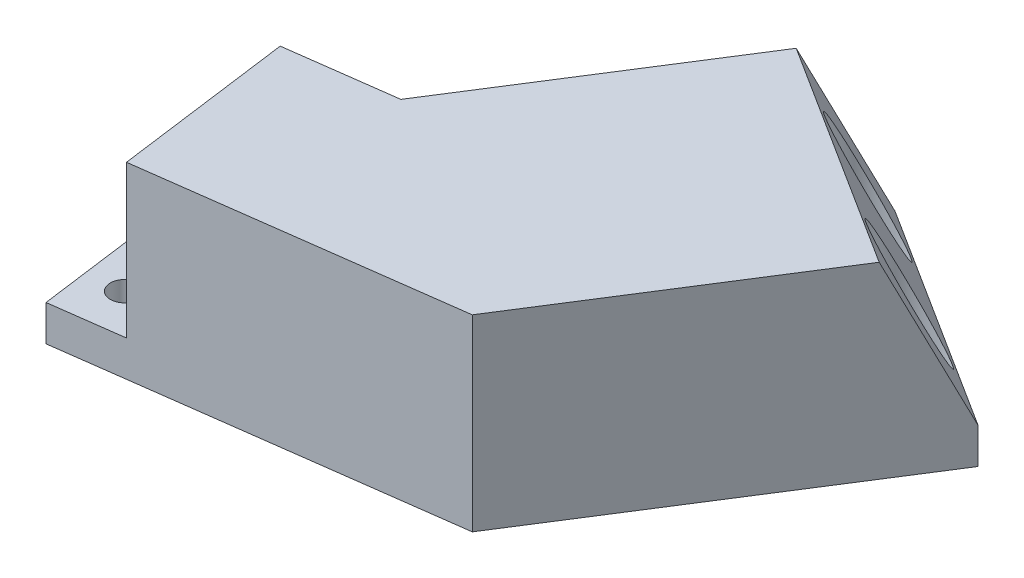
from build123d import *

# Parameters (mm, degrees)
BOSS_EXTRUDE1_DEPTH = 21
CUT_EXTRUDE1_DEPTH  = 17
CUT_EXTRUDE2_START  = -3
CUT_EXTRUDE2_DEPTH  = 19
SKETCH4_R           = 4.5
CUT_EXTRUDE3_DEPTH  = 38.831838053
SKETCH5_R           = 1.6
CUT_EXTRUDE4_DEPTH  = 5
CUT_EXTRUDE5_DEPTH  = 0.5
BOSS_EXTRUDE2_DEPTH = 30
SKETCH10_R          = 1.6
CUT_EXTRUDE6_DEPTH  = 22
CUT_EXTRUDE7_START  = -4
SKETCH11_R          = 3.5
CUT_EXTRUDE7_DEPTH  = 18
SKETCH12_R          = 3
CUT_EXTRUDE8_DEPTH  = 14.628403502
CUT_EXTRUDE9_DEPTH  = 0.5


with BuildPart() as part:
    # Sketch1 → Boss-Extrude1 (new body)
    with BuildSketch(Plane(origin=(0, 0, 0), x_dir=(1, 0, 0), z_dir=(0, 1, 0))):
        Polygon((0, 0), (-19.823417158, -2.651816769), (-17.171600389, -22.475233927), (24.834444629, -16.856004221), (46.756935141, 17.714090893), (21.421674862, 33.78034704), align=None)
    extrude(amount=BOSS_EXTRUDE1_DEPTH)

    # Sketch2 → Cut-Extrude1 (cut)
    with BuildSketch(Plane(origin=(0, 21, 0), x_dir=(1, 0, 0), z_dir=(0, 1, 0))):
        Polygon((21.421674862, 33.78034704), (17.137339889, 27.024277632), (42.472600169, 10.958021485), (46.756935141, 17.714090893), align=None)
        Polygon((-19.823417158, -2.651816769), (-17.171600389, -22.475233927), (-9.242233526, -21.414507219), (-11.894050295, -1.591090061), align=None)
    extrude(amount=-CUT_EXTRUDE1_DEPTH, mode=Mode.SUBTRACT)

    # Sketch3 → Cut-Extrude2 (cut, through all)
    with BuildSketch(Plane(origin=(0, 21, 0), x_dir=(1, 0, 0), z_dir=(0, 1, 0)).offset(CUT_EXTRUDE2_START)):
        Polygon((23.050100429, -14.067976017), (38.332448526, 10.031121072), (18.064240303, 22.884125989), (1.7843442, -2.788028204), (-8.522765206, -4.16683012), (-6.666493468, -18.04322213), align=None)
    extrude(amount=-CUT_EXTRUDE2_DEPTH, mode=Mode.SUBTRACT)

    # Sketch4 → Cut-Extrude3 (cut, through all)
    with BuildSketch(Plane(origin=(2.533526028, 0, 1.606625615), x_dir=(0.535541872, 0, -0.844508676), z_dir=(0.844508676, 0, 0.535541872))):
        with Locations((13.800538513, 9)):
            Circle(SKETCH4_R)
    extrude(amount=-CUT_EXTRUDE3_DEPTH, mode=Mode.SUBTRACT)

    # Sketch5 → Cut-Extrude4 (cut, through all)
    with BuildSketch(Plane(origin=(0, 4, 0), x_dir=(1, 0, 0), z_dir=(0, 1, 0))):
        with Locations((26.035576783, 26.117977363)):
            Circle(SKETCH5_R)
        with Locations((38.703206923, 18.08484929)):
            Circle(SKETCH5_R)
        with Locations((-15.195779534, -7.077307705)):
            Circle(SKETCH5_R)
        with Locations((-13.86987115, -16.989016284)):
            Circle(SKETCH5_R)
    extrude(amount=-CUT_EXTRUDE4_DEPTH, mode=Mode.SUBTRACT)

    # Sketch6 → Cut-Extrude5 (cut)
    with BuildSketch(Plane(origin=(0, 0, 0), x_dir=(-0.535541872, 0, 0.844508676), z_dir=(-0.844508676, 0, -0.535541872))):
        Polygon((-24, 7.5), (-24, 6.888221154), (-24.692307692, 6.635216346), (-24.692307692, 5.483774038), (-24, 5.230769231), (-24, 4.615384615), (-27, 5.749399038), (-27, 6.360576923), align=None)
        Polygon((-25.192307692, 6.451923077), (-26.269230769, 6.057692308), (-25.192307692, 5.664663462), align=None, mode=Mode.SUBTRACT)
        Polygon((-24, 7.923076923), (-27, 7.923076923), (-27, 8.5), (-24.5, 8.5), (-24.5, 10.038461538), (-24, 10.038461538), align=None)
        Polygon((-24, 11.153846154), (-26.5, 11.153846154), (-26.5, 10.269230769), (-27, 10.269230769), (-27, 12.615384615), (-26.5, 12.615384615), (-26.5, 11.730769231), (-24, 11.730769231), align=None)
    extrude(amount=-CUT_EXTRUDE5_DEPTH, mode=Mode.SUBTRACT)

    # Sketch8 → Boss-Extrude2 (add)
    with BuildSketch(Plane(origin=(0, 0, 0), x_dir=(-0.535541872, 0, 0.844508676), z_dir=(-0.844508676, 0, -0.535541872))):
        Polygon((-40, 4), (-32, 21), (-32, 4), align=None)
    extrude(amount=-BOSS_EXTRUDE2_DEPTH)

    # Sketch10 → Cut-Extrude6 (cut, through all)
    with BuildSketch(Plane.XZ):
        with Locations((26.035576783, -26.117977363)):
            Circle(SKETCH10_R)
        with Locations((38.703206923, -18.08484929)):
            Circle(SKETCH10_R)
        with Locations((-15.195779534, 7.077307705)):
            Circle(SKETCH10_R)
        with Locations((-13.86987115, 16.989016284)):
            Circle(SKETCH10_R)
    extrude(amount=-CUT_EXTRUDE6_DEPTH, mode=Mode.SUBTRACT)

    # Sketch11 → Cut-Extrude7 (cut, through all)
    with BuildSketch(Plane.XZ.offset(CUT_EXTRUDE7_START)):
        with Locations((-15.195779534, 7.077307705)):
            Circle(SKETCH11_R)
        with Locations((-13.86987115, 16.989016284)):
            Circle(SKETCH11_R)
        with Locations((38.703206923, -18.08484929)):
            Circle(SKETCH11_R)
        with Locations((26.035576783, -26.117977363)):
            Circle(SKETCH11_R)
    extrude(amount=-CUT_EXTRUDE7_DEPTH, mode=Mode.SUBTRACT)

    # Sketch12 → Cut-Extrude8 (cut, through all)
    with BuildSketch(Plane(origin=(-8.920537721, 0, 1.193317546), x_dir=(-0.132590838, 0, -0.991170858), z_dir=(0.991170858, 0, -0.132590838))):
        with Locations((-10, 11)):
            Circle(SKETCH12_R)
    extrude(amount=-CUT_EXTRUDE8_DEPTH, mode=Mode.SUBTRACT)

    # Sketch13 → Cut-Extrude9 (cut)
    with BuildSketch(Plane(origin=(0, 0, 0), x_dir=(-0.991170858, 0, 0.132590838), z_dir=(-0.132590838, 0, -0.991170858))):
        with BuildLine():
            Line((7, 6.076923077), (4, 6.076923077))
            Line((4, 6.076923077), (4, 7.3359375))
            add(Edge.make_bspline(
                [(4, 7.3359375), (4.000235812, 7.374200193), (4.000690265, 7.447939405), (4.004004228, 7.554580691), (4.010947173, 7.652927894), (4.018810115, 7.743417285), (4.030250189, 7.825614235), (4.043955285, 7.899843736), (4.059837601, 7.965980819), (4.078859251, 8.024990461), (4.10063019, 8.078795267), (4.126543733, 8.128917084), (4.156904633, 8.175907015), (4.190666434, 8.220486781), (4.227881012, 8.262845158), (4.269533248, 8.301820904), (4.315002928, 8.338093081), (4.363911741, 8.371632422), (4.416043725, 8.401178482), (4.46972465, 8.428175823), (4.525525761, 8.450152677), (4.583184194, 8.468305359), (4.642574764, 8.482806001), (4.703848464, 8.492870672), (4.766894386, 8.499153938), (4.809480079, 8.499714845), (4.831129808, 8.5)],
                knots=[0, 0, 0, 0, 0.00011479, 0.000221221, 0.00032, 0.000410536, 0.000493656, 0.000568856, 0.000636924, 0.000697549, 0.000754688, 0.000810864, 0.000866543, 0.000922313, 0.000978509, 0.001035476, 0.001093197, 0.001152871, 0.001213174, 0.001272839, 0.001332989, 0.00139286, 0.001454078, 0.001516222, 0.00157901, 0.001643939, 0.001643939, 0.001643939, 0.001643939], degree=3))
            add(Edge.make_bspline(
                [(4.831129808, 8.5), (4.858402406, 8.499471081), (4.91170058, 8.498437428), (4.989819116, 8.488925203), (5.064455802, 8.474797119), (5.135714038, 8.454657645), (5.202755727, 8.426966278), (5.266520028, 8.394819986), (5.32679065, 8.356480132), (5.382970103, 8.312207194), (5.435108117, 8.262040808), (5.482131731, 8.205761125), (5.524224725, 8.143769964), (5.561144365, 8.075692317), (5.592706657, 8.002002212), (5.619262207, 7.922380104), (5.640875467, 7.837186444), (5.651045152, 7.777925781), (5.65625, 7.747596154)],
                knots=[0, 0, 0, 0, 8.1786e-05, 0.000159832, 0.000235735, 0.000309533, 0.000381513, 0.000453005, 0.000523525, 0.00059542, 0.000667247, 0.000740191, 0.000815032, 0.000891675, 0.000972163, 0.001055211, 0.001143248, 0.00123554, 0.00123554, 0.00123554, 0.00123554], degree=3))
            add(Edge.make_bspline(
                [(5.65625, 7.747596154), (5.675681616, 7.776922961), (5.713711936, 7.834319518), (5.77626824, 7.913821099), (5.842126149, 7.984753025), (5.899872584, 8.039560781), (5.951807966, 8.080139742), (5.996263362, 8.114181465), (6.04809867, 8.150108812), (6.10704632, 8.188092911), (6.171941789, 8.230022035), (6.24408668, 8.273549124), (6.322779752, 8.319893651), (6.377757076, 8.351043543), (6.40625, 8.3671875)],
                knots=[0, 0, 0, 0, 0.000105513, 0.000206503, 0.000303041, 0.000395741, 0.000444921, 0.000500691, 0.000563709, 0.000634049, 0.000711069, 0.00079548, 0.000886798, 0.000985042, 0.000985042, 0.000985042, 0.000985042], degree=3))
            Line((6.40625, 8.3671875), (7, 8.730769231))
            Line((7, 8.730769231), (7, 8.056490385))
            Line((7, 8.056490385), (6.319110577, 7.629807692))
            add(Edge.make_bspline(
                [(6.319110577, 7.629807692), (6.291837494, 7.610217046), (6.239767571, 7.572814474), (6.165836225, 7.518740691), (6.099941609, 7.46964023), (6.041770639, 7.425469214), (5.991435697, 7.386296201), (5.949534868, 7.351188556), (5.914684117, 7.321975782), (5.880205707, 7.288849138), (5.844554664, 7.250605119), (5.811089818, 7.202334131), (5.782712277, 7.153974388), (5.761995083, 7.101300929), (5.747329663, 7.040702622), (5.738059904, 6.967785201), (5.731192407, 6.880336999), (5.73091744, 6.817124792), (5.730769231, 6.783052885)],
                knots=[0, 0, 0, 0, 0.00010074, 0.000192332, 0.000274785, 0.000347262, 0.000411461, 0.000466093, 0.000511265, 0.00054782, 0.000609508, 0.000667702, 0.000723682, 0.00077736, 0.000836828, 0.000910258, 0.000997648, 0.001099827, 0.001099827, 0.001099827, 0.001099827], degree=3))
            Line((5.730769231, 6.783052885), (5.730769231, 6.653846154))
            Line((5.730769231, 6.653846154), (7, 6.653846154))
            Line((7, 6.653846154), (7, 6.076923077))
        make_face()
        with BuildLine():
            Line((5.230769231, 6.653846154), (5.230769231, 7.118389423))
            add(Edge.make_bspline(
                [(5.230769231, 7.118389423), (5.230692383, 7.154248526), (5.230545974, 7.222566178), (5.228425298, 7.319715234), (5.226625367, 7.406502064), (5.222102924, 7.482407269), (5.21762084, 7.547770591), (5.211795498, 7.60232943), (5.20491083, 7.646544569), (5.194204583, 7.690705463), (5.175563443, 7.735954926), (5.148962561, 7.784124825), (5.114536379, 7.825610606), (5.074195803, 7.86066775), (5.027787064, 7.888499499), (4.976083484, 7.909582749), (4.918313674, 7.920447588), (4.87824354, 7.922182114), (4.857572115, 7.923076923)],
                knots=[0, 0, 0, 0, 0.000107574, 0.000204946, 0.000291518, 0.000367956, 0.000433038, 0.000488054, 0.000532513, 0.000567203, 0.000624117, 0.000678755, 0.000731694, 0.00078495, 0.000838337, 0.000893354, 0.000951576, 0.001013618, 0.001013618, 0.001013618, 0.001013618], degree=3))
            add(Edge.make_bspline(
                [(4.857572115, 7.923076923), (4.834445963, 7.922063841), (4.789827781, 7.920109262), (4.726218231, 7.904397792), (4.669821654, 7.87754876), (4.620899936, 7.840293903), (4.580386892, 7.793113632), (4.547613004, 7.737626772), (4.523313578, 7.673327625), (4.514317006, 7.626983781), (4.509615385, 7.602764423)],
                knots=[0, 0, 0, 0, 6.9322e-05, 0.000133745, 0.000195032, 0.00025549, 0.00031683, 0.000380421, 0.000447946, 0.000521864, 0.000521864, 0.000521864, 0.000521864], degree=3))
            add(Edge.make_bspline(
                [(4.509615385, 7.602764423), (4.508735622, 7.594757737), (4.506650399, 7.57578021), (4.505311153, 7.542268148), (4.503252585, 7.499418676), (4.502411294, 7.446713146), (4.500936585, 7.384622425), (4.500665791, 7.312899613), (4.499800624, 7.231772579), (4.499931109, 7.174479514), (4.5, 7.144230769)],
                knots=[0, 0, 0, 0, 2.4158e-05, 5.726e-05, 0.000100567, 0.000152865, 0.000215376, 0.000286893, 0.000368025, 0.00045877, 0.00045877, 0.00045877, 0.00045877], degree=3))
            Line((4.5, 7.144230769), (4.5, 6.653846154))
            Line((4.5, 6.653846154), (5.230769231, 6.653846154))
        make_face(mode=Mode.SUBTRACT)
        Polygon((7, 9.911057692), (4, 10.642427885), (4, 11.076923077), (7, 10.346153846), align=None)
        with BuildLine():
            Line((4, 12.538461538), (4, 13.746995192))
            add(Edge.make_bspline(
                [(4, 13.746995192), (4.000170161, 13.776041606), (4.000498762, 13.832133558), (4.001464608, 13.913478934), (4.004074122, 13.988994803), (4.006822857, 14.058734843), (4.010984406, 14.12266265), (4.016470454, 14.18094803), (4.022428444, 14.233647378), (4.030748525, 14.295989776), (4.047098764, 14.367960548), (4.0742283, 14.449711092), (4.108980932, 14.526826795), (4.152021512, 14.599090011), (4.203377393, 14.665912124), (4.262265373, 14.727377874), (4.329380713, 14.782587938), (4.403299374, 14.831428654), (4.483531318, 14.873112811), (4.570036975, 14.901400198), (4.660887714, 14.919760511), (4.723065264, 14.921956065), (4.754807692, 14.923076923)],
                knots=[0, 0, 0, 0, 8.7141e-05, 0.00016828, 0.00024404, 0.000313816, 0.000377656, 0.0004362, 0.000489425, 0.000536764, 0.000624827, 0.000710345, 0.000794797, 0.000878073, 0.000962091, 0.001047097, 0.001132892, 0.001222231, 0.001312535, 0.001403185, 0.001494409, 0.00158955, 0.00158955, 0.00158955, 0.00158955], degree=3))
            add(Edge.make_bspline(
                [(4.754807692, 14.923076923), (4.789365979, 14.921883277), (4.857703614, 14.919522888), (4.957728703, 14.898352882), (5.053224181, 14.863781027), (5.142835272, 14.815687512), (5.225185697, 14.756536189), (5.297508719, 14.686605431), (5.35935154, 14.606883837), (5.390125082, 14.547023794), (5.405649038, 14.516826923)],
                knots=[0, 0, 0, 0, 0.000103577, 0.000204819, 0.000305195, 0.000407359, 0.000508937, 0.000608389, 0.000708273, 0.000809955, 0.000809955, 0.000809955, 0.000809955], degree=3))
            add(Edge.make_bspline(
                [(5.405649038, 14.516826923), (5.412576448, 14.537165171), (5.426273718, 14.57737912), (5.451425822, 14.6349392), (5.480594632, 14.688869878), (5.512860358, 14.739144072), (5.548458875, 14.786143347), (5.588570545, 14.828494568), (5.630913304, 14.868627871), (5.677612633, 14.903861798), (5.726434974, 14.93575391), (5.778144498, 14.962825546), (5.831497456, 14.986267328), (5.887033815, 15.005872125), (5.945126057, 15.019846923), (6.00504237, 15.031044402), (6.067198013, 15.036772719), (6.109165468, 15.037893977), (6.130408654, 15.038461538)],
                knots=[0, 0, 0, 0, 6.4438e-05, 0.00012741, 0.000188178, 0.00024819, 0.000306486, 0.000364742, 0.000422999, 0.000481295, 0.000539971, 0.00059777, 0.000656165, 0.000714703, 0.00077417, 0.000835232, 0.000897422, 0.00096117, 0.00096117, 0.00096117, 0.00096117], degree=3))
            add(Edge.make_bspline(
                [(6.130408654, 15.038461538), (6.164328604, 15.037234777), (6.232209309, 15.03477978), (6.333251827, 15.017032989), (6.432366161, 14.986306604), (6.528989793, 14.945293052), (6.620251766, 14.894146259), (6.703526581, 14.83399784), (6.776086364, 14.764077381), (6.839312415, 14.686015892), (6.892107735, 14.598565797), (6.933593063, 14.501525597), (6.964070424, 14.394885473), (6.974297615, 14.319891576), (6.979567308, 14.28125)],
                knots=[0, 0, 0, 0, 0.00010174, 0.000203603, 0.000306639, 0.000412458, 0.000517935, 0.000619866, 0.000719751, 0.000819331, 0.000920437, 0.001025151, 0.001135106, 0.001251985, 0.001251985, 0.001251985, 0.001251985], degree=3))
            add(Edge.make_bspline(
                [(6.979567308, 14.28125), (6.980817451, 14.266430041), (6.983687252, 14.232409686), (6.987255193, 14.174713054), (6.98995216, 14.103772186), (6.993140981, 14.019648678), (6.995443404, 13.922083562), (6.997015647, 13.811298575), (6.999056109, 13.687104689), (6.999674478, 13.599960808), (7, 13.554086538)],
                knots=[0, 0, 0, 0, 4.4617e-05, 0.000102422, 0.000173399, 0.000257587, 0.000354973, 0.000466165, 0.000589976, 0.000727602, 0.000727602, 0.000727602, 0.000727602], degree=3))
            Line((7, 13.554086538), (7, 12.538461538))
            Line((7, 12.538461538), (4, 12.538461538))
        make_face()
        with BuildLine():
            Line((4.5, 13.115384615), (5.192307692, 13.115384615))
            Line((5.192307692, 13.115384615), (5.192307692, 13.533052885))
            add(Edge.make_bspline(
                [(5.192307692, 13.533052885), (5.192372568, 13.562500261), (5.192496143, 13.618591255), (5.191668048, 13.698317089), (5.191281458, 13.769435571), (5.190146872, 13.831742234), (5.188274386, 13.885224286), (5.186404556, 13.929689023), (5.184988879, 13.965393391), (5.182967356, 13.986183215), (5.182091346, 13.995192308)],
                knots=[0, 0, 0, 0, 8.8341e-05, 0.000168271, 0.000239187, 0.000301699, 0.000355215, 0.000399723, 0.000435225, 0.000462375, 0.000462375, 0.000462375, 0.000462375], degree=3))
            add(Edge.make_bspline(
                [(5.182091346, 13.995192308), (5.178186422, 14.021177017), (5.170681399, 14.071118035), (5.148603211, 14.14094049), (5.116910052, 14.201833429), (5.076530074, 14.253183735), (5.028536481, 14.295100598), (4.972559261, 14.325143608), (4.909116017, 14.342920209), (4.864499686, 14.345049076), (4.841346154, 14.346153846)],
                knots=[0, 0, 0, 0, 7.8747e-05, 0.000151346, 0.000218549, 0.000283592, 0.000346233, 0.000408345, 0.000472651, 0.000542022, 0.000542022, 0.000542022, 0.000542022], degree=3))
            add(Edge.make_bspline(
                [(4.841346154, 14.346153846), (4.819206022, 14.345406982), (4.776324099, 14.343960426), (4.715586889, 14.327827597), (4.661179283, 14.302202922), (4.613729588, 14.26635641), (4.574011801, 14.22031674), (4.542951927, 14.164352979), (4.521610792, 14.098351359), (4.514141832, 14.050821681), (4.510216346, 14.025841346)],
                knots=[0, 0, 0, 0, 6.628e-05, 0.000128375, 0.000186974, 0.000245748, 0.000305392, 0.000368082, 0.000436497, 0.000512287, 0.000512287, 0.000512287, 0.000512287], degree=3))
            add(Edge.make_bspline(
                [(4.510216346, 14.025841346), (4.509337683, 14.016030633), (4.507260366, 13.992836348), (4.505909958, 13.952524395), (4.504009348, 13.901249964), (4.502154449, 13.838751697), (4.50102193, 13.765027903), (4.500640233, 13.680288255), (4.499808522, 13.584536537), (4.49993382, 13.517027469), (4.5, 13.481370192)],
                knots=[0, 0, 0, 0, 2.9545e-05, 6.985e-05, 0.000120963, 0.000183489, 0.000257417, 0.000342155, 0.00043771, 0.000544681, 0.000544681, 0.000544681, 0.000544681], degree=3))
            Line((4.5, 13.481370192), (4.5, 13.115384615))
        make_face(mode=Mode.SUBTRACT)
        with BuildLine():
            Line((5.692307692, 13.115384615), (6.5, 13.115384615))
            Line((6.5, 13.115384615), (6.5, 13.704326923))
            add(Edge.make_bspline(
                [(6.5, 13.704326923), (6.500136143, 13.731772193), (6.500394532, 13.783861365), (6.498663874, 13.858169853), (6.498093213, 13.92450507), (6.495246152, 13.983177493), (6.49309238, 14.03387881), (6.490407341, 14.076817642), (6.486137355, 14.111658723), (6.48282235, 14.132219287), (6.481370192, 14.141225962)],
                knots=[0, 0, 0, 0, 8.2332e-05, 0.00015626, 0.000222977, 0.00028132, 0.000332458, 0.000375232, 0.000410341, 0.00043771, 0.00043771, 0.00043771, 0.00043771], degree=3))
            add(Edge.make_bspline(
                [(6.481370192, 14.141225962), (6.476547595, 14.164101561), (6.467177665, 14.208547067), (6.440226299, 14.270094033), (6.406202399, 14.325887082), (6.361707027, 14.373303974), (6.309729253, 14.413451274), (6.248387707, 14.441726475), (6.179024512, 14.458988662), (6.130115531, 14.460663558), (6.104567308, 14.461538462)],
                knots=[0, 0, 0, 0, 6.9962e-05, 0.000135931, 0.000200461, 0.000265103, 0.000329887, 0.00039629, 0.000466252, 0.000542766, 0.000542766, 0.000542766, 0.000542766], degree=3))
            add(Edge.make_bspline(
                [(6.104567308, 14.461538462), (6.082657928, 14.460836355), (6.040013878, 14.459469785), (5.978792217, 14.445813212), (5.92266934, 14.424198901), (5.872320302, 14.393797668), (5.827626858, 14.355360798), (5.789755407, 14.308580939), (5.758208136, 14.254257098), (5.737531878, 14.202489375), (5.723924945, 14.153494273), (5.716395144, 14.106478635), (5.708082687, 14.050274555), (5.702751871, 13.984427646), (5.697631523, 13.909119327), (5.69526074, 13.824324411), (5.692357132, 13.729986725), (5.692324695, 13.663865308), (5.692307692, 13.629206731)],
                knots=[0, 0, 0, 0, 6.564e-05, 0.00012776, 0.000187131, 0.000245362, 0.00030331, 0.000363099, 0.000425045, 0.00049111, 0.000529745, 0.000577369, 0.000633802, 0.00070018, 0.000775454, 0.000860243, 0.000954624, 0.001058592, 0.001058592, 0.001058592, 0.001058592], degree=3))
            Line((5.692307692, 13.629206731), (5.692307692, 13.115384615))
        make_face(mode=Mode.SUBTRACT)
    extrude(amount=-CUT_EXTRUDE9_DEPTH, mode=Mode.SUBTRACT)


solid = part.part
